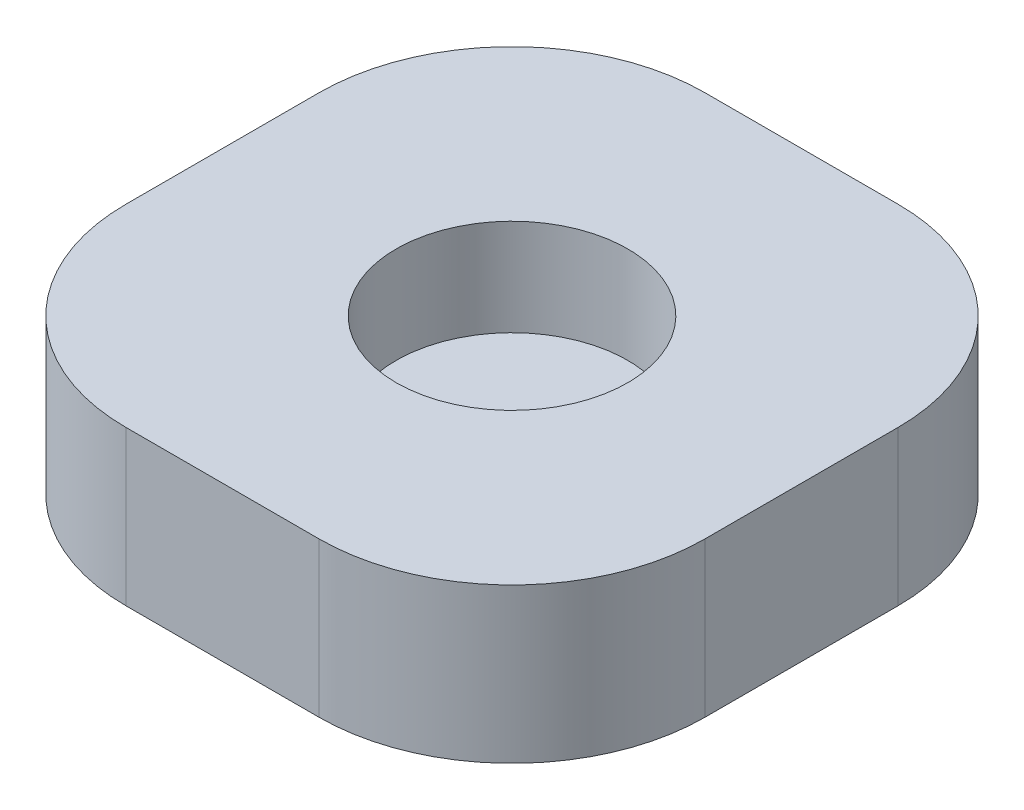
from build123d import *

# Parameters (mm, degrees)
BOSS_EXTRUDE1_DEPTH = 4
SKETCH2_R           = 3
CUT_EXTRUDE1_DEPTH  = 2.5


with BuildPart() as part:
    # Sketch1 → Boss-Extrude1 (new body)
    with BuildSketch(Plane(origin=(0, 0, 0), x_dir=(1, 0, 0), z_dir=(0, 1, 0))):
        with BuildLine():
            Line((-2.5, -7.5), (2.5, -7.5))
            ThreePointArc((2.5, -7.5), (6.035533906, -6.035533906), (7.5, -2.5))
            Line((7.5, -2.5), (7.5, 2.5))
            ThreePointArc((7.5, 2.5), (6.035533906, 6.035533906), (2.5, 7.5))
            Line((2.5, 7.5), (-2.5, 7.5))
            ThreePointArc((-2.5, 7.5), (-6.035533906, 6.035533906), (-7.5, 2.5))
            Line((-7.5, 2.5), (-7.5, -2.5))
            ThreePointArc((-7.5, -2.5), (-6.035533906, -6.035533906), (-2.5, -7.5))
        make_face()
    extrude(amount=BOSS_EXTRUDE1_DEPTH)

    # Sketch2 → Cut-Extrude1 (cut)
    with BuildSketch(Plane(origin=(0, 4, 0), x_dir=(1, 0, 0), z_dir=(0, 1, 0))):
        Circle(SKETCH2_R)
    extrude(amount=-CUT_EXTRUDE1_DEPTH, mode=Mode.SUBTRACT)


solid = part.part
